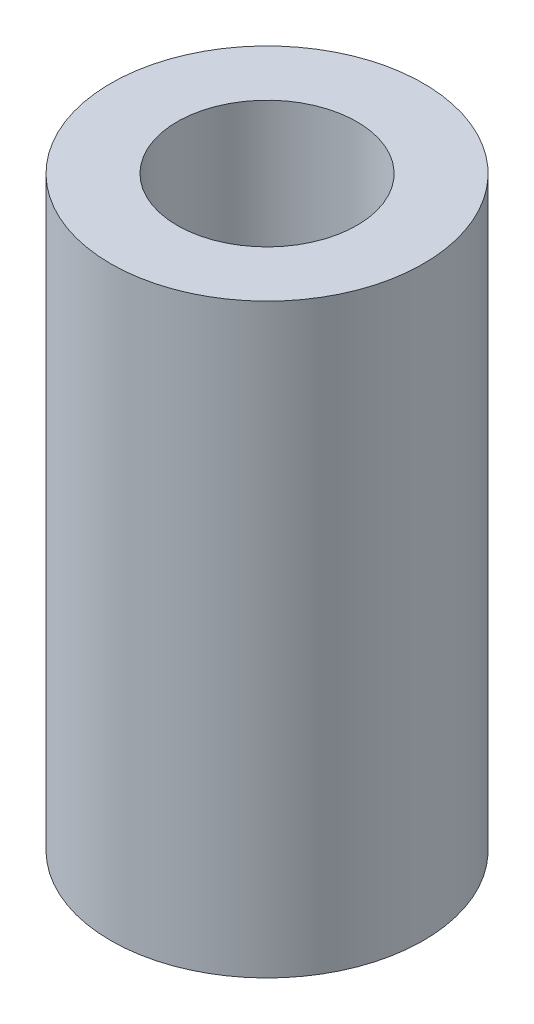
from build123d import *

# Parameters (mm, degrees)
SKETCH1_R           = 4
SKETCH1_R_2         = 2.3
BOSS_EXTRUDE1_DEPTH = 15


with BuildPart() as part:
    # Sketch1 → Boss-Extrude1 (new body)
    with BuildSketch(Plane(origin=(0, 0, 0), x_dir=(1, 0, 0), z_dir=(0, 1, 0))):
        Circle(SKETCH1_R)
        Circle(SKETCH1_R_2, mode=Mode.SUBTRACT)
    extrude(amount=BOSS_EXTRUDE1_DEPTH)


solid = part.part
